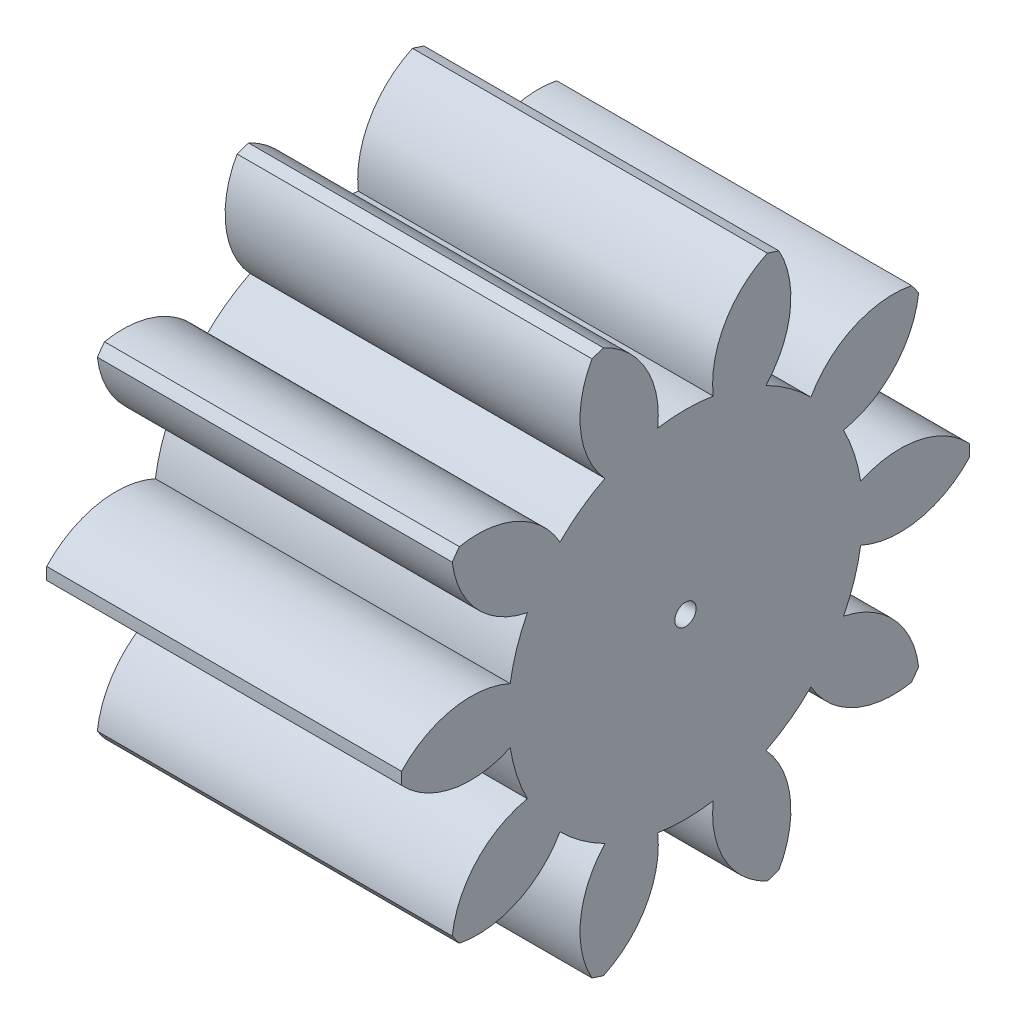
from build123d import *

# Parameters (mm, degrees)
BASPROSKE_W     = 15
BASPROSKE_H     = 12
TOOTHCUT_DEPTH  = 23.649503306
TEETHCUTS_COUNT = 10
TEETHCUTS_ANGLE = 324
BORSKE_R        = 0.45
BORE_DEPTH      = 50.0000508


with BuildPart() as part:
    # BasProSke → Base-Revolve (revolve)
    with BuildSketch(Plane(origin=(0, 0, 0), x_dir=(1, 0, 0), z_dir=(0, 1, 0)), mode=Mode.PRIVATE) as base_revolve_sk:
        with Locations((7.5, 6)):
            Rectangle(BASPROSKE_W, BASPROSKE_H)
    revolve(base_revolve_sk.sketch.rotate(Axis((-10, 0, 0), (1, 0, 0)), 180), axis=Axis((-10, 0, 0), (1, 0, 0)))

    # TooCutSke → ToothCut (cut, through all)
    with BuildSketch(Plane(origin=(0, 0, 0), x_dir=(0, 0, -1), z_dir=(1, 0, 0))):
        with BuildLine():
            ThreePointArc((1.173662691, 7.406586048), (0, 7.499), (-1.173662691, 7.406586048))
            ThreePointArc((-1.173662691, 7.406586048), (-1.668191438, 9.834565786), (-3.497907776, 11.50542856))
            ThreePointArc((-3.497907776, 11.50542856), (0, 12.0254), (3.497907776, 11.50542856))
            ThreePointArc((3.497907776, 11.50542856), (1.668191438, 9.834565786), (1.173662691, 7.406586048))
        make_face()
    toothcut = extrude(amount=TOOTHCUT_DEPTH, mode=Mode.SUBTRACT)

    # TeethCuts: ToothCut ×10 about axis
    teethcuts_axis = Axis((-10, 0, 0), (1, 0, 0))
    for i in range(1, TEETHCUTS_COUNT):
        add(toothcut.rotate(teethcuts_axis, i * TEETHCUTS_ANGLE / (TEETHCUTS_COUNT - 1)), mode=Mode.SUBTRACT)

    # BorSke → Bore (cut, symmetric)
    with BuildSketch(Plane(origin=(0, 0, 0), x_dir=(0, 0, -1), z_dir=(1, 0, 0))):
        with Locations(Location((0, 0, 0), (0, 0, 180))):
            Circle(BORSKE_R)
    extrude(amount=BORE_DEPTH, both=True, mode=Mode.SUBTRACT)


solid = part.part
